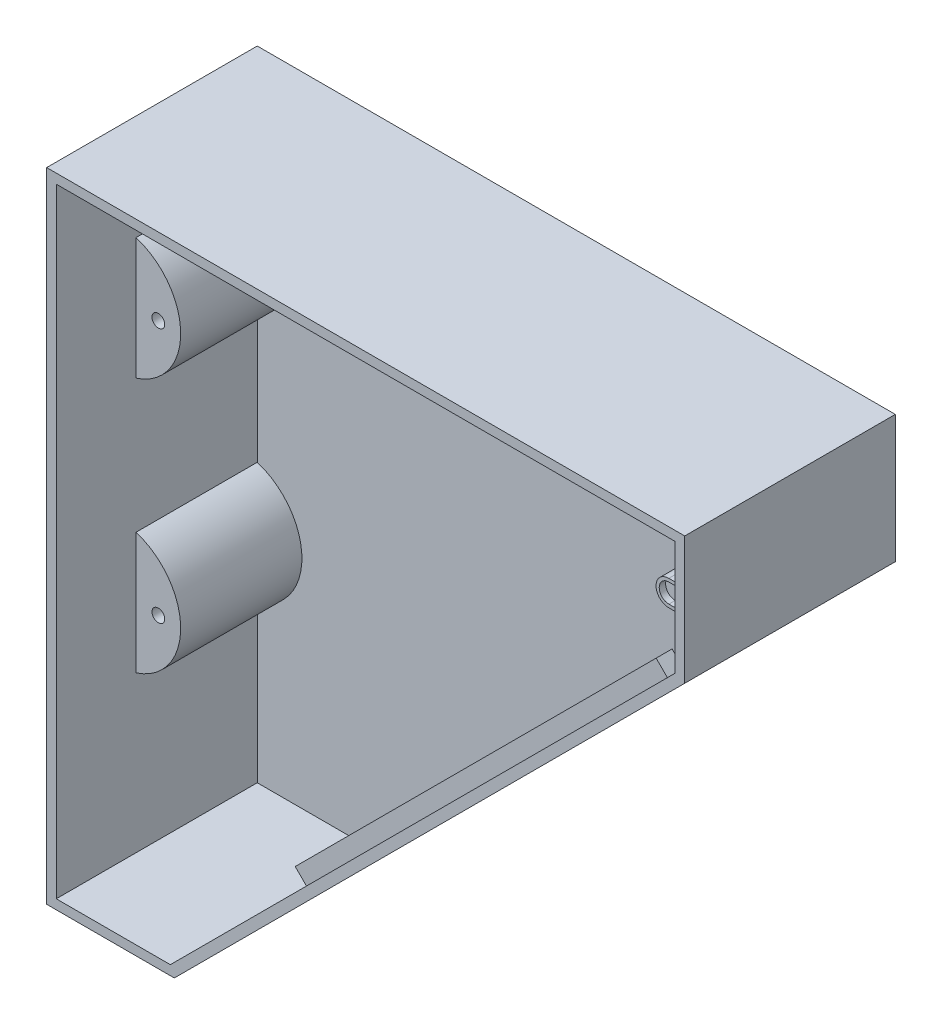
from build123d import *

# Parameters (mm, degrees)
ESTRUSIONE_ESTRUSIONE1_DEPTH  = 70
SVUOTA1_T                     = -3
SCHIZZO5_W                    = 4
SCHIZZO5_H                    = 200
TAGLIO_ESTRUSIONE1_DEPTH      = 1
TAGLIO_ESTRUSIONE1_DEPTH_BACK = 201
ESTRUSIONE_ESTRUSIONE4_DEPTH  = 38
SCHIZZO8_R                    = 2
TAGLIO_ESTRUSIONE2_DEPTH      = 30
SCHIZZO11_W                   = 160
SCHIZZO11_H                   = 5
ESTRUSIONE_ESTRUSIONE7_DEPTH  = 5
ESTRUSIONE_ESTRUSIONE8_DEPTH  = 62
ESTRUSIONE_ESTRUSIONE9_DEPTH  = 2


with BuildPart() as part:
    # Schizzo2 → Estrusione-Estrusione1 (new body)
    with BuildSketch(Plane.XY):
        Polygon((0, 0), (0, 200), (200, 200), (200, 160), (40, 0), align=None)
    extrude(amount=ESTRUSIONE_ESTRUSIONE1_DEPTH)

    # Svuota1
    svuota1_openings = [part.faces().sort_by_distance(p)[0] for p in [
        (88, 112, 70),
    ]]
    offset(amount=SVUOTA1_T, openings=svuota1_openings, kind=Kind.INTERSECTION)

    # Schizzo5 → Taglio-Estrusione1 (cut, two sides)
    with BuildSketch(Plane(origin=(200, 0, 0), x_dir=(0, 0, -1), z_dir=(1, 0, 0))) as taglio_estrusione1_sk:
        with Locations((-68, 100)):
            Rectangle(SCHIZZO5_W, SCHIZZO5_H)
    extrude(amount=TAGLIO_ESTRUSIONE1_DEPTH, mode=Mode.SUBTRACT)
    extrude(taglio_estrusione1_sk.sketch, amount=-TAGLIO_ESTRUSIONE1_DEPTH_BACK, mode=Mode.SUBTRACT)

    # Schizzo7 → Estrusione-Estrusione4 (add)
    with BuildSketch(Plane.XY.offset(41)):
        with BuildLine():
            Line((3, 170), (3, 131.842431943))
            ThreePointArc((3, 131.842431943), (17, 150.921215972), (3, 170))
        make_face()
        with BuildLine():
            Line((3, 90), (3, 51.842431943))
            ThreePointArc((3, 51.842431943), (17, 70.921215972), (3, 90))
        make_face()
    extrude(amount=-ESTRUSIONE_ESTRUSIONE4_DEPTH)

    # Schizzo8 → Taglio-Estrusione2 (cut)
    with BuildSketch(Plane.XY.offset(41)):
        with Locations((10, 150.921215972)):
            Circle(SCHIZZO8_R)
        with Locations((10, 70.921215972)):
            Circle(SCHIZZO8_R)
    extrude(amount=-TAGLIO_ESTRUSIONE2_DEPTH, mode=Mode.SUBTRACT)

    # Schizzo11 → Estrusione-Estrusione7 (add)
    with BuildSketch(Plane.XY.offset(41)):
        with Locations((108, 194.5)):
            Rectangle(SCHIZZO11_W, SCHIZZO11_H)
        Polygon((169.572113832, 133.81475452), (56.435028843, 20.67766953), (52.899494937, 24.213203436), (166.036579926, 137.350288425), align=None)
    extrude(amount=-ESTRUSIONE_ESTRUSIONE7_DEPTH)

    # Schizzo12 → Estrusione-Estrusione8 (add)
    with BuildSketch(Plane.XY.offset(62)):
        with BuildLine():
            Line((193, 184), (197, 184))
            Line((197, 184), (197, 176))
            Line((197, 176), (193, 176))
            ThreePointArc((193, 176), (189, 180), (193, 184))
        make_face()
    extrude(amount=-ESTRUSIONE_ESTRUSIONE8_DEPTH)

    # Schizzo13 → Estrusione-Estrusione9 (add)
    with BuildSketch(Plane.XY.offset(62)):
        with BuildLine():
            Line((193, 177), (196, 177))
            Line((196, 177), (197, 177))
            Line((197, 177), (197, 176))
            Line((197, 176), (193, 176))
            ThreePointArc((193, 176), (189, 180), (193, 184))
            Line((193, 184), (197, 184))
            Line((197, 184), (197, 183))
            Line((197, 183), (193, 183))
            ThreePointArc((193, 183), (190, 180), (193, 177))
        make_face()
    extrude(amount=ESTRUSIONE_ESTRUSIONE9_DEPTH)


solid = part.part
